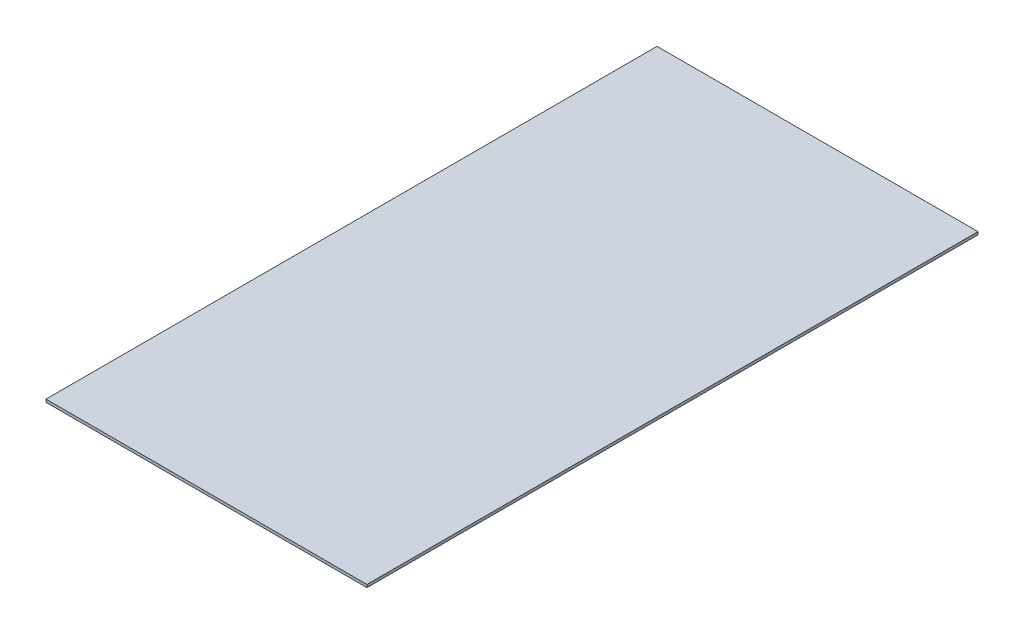
from build123d import *

# Parameters (mm, degrees)
SKETCH_1_W      = 229
SKETCH_1_H      = 436
EXTRUDE_1_DEPTH = 2


with BuildPart() as part:
    # 草图1 → 凸台-拉伸1 (new body)
    with BuildSketch(Plane(origin=(0, 0, 0), x_dir=(1, 0, 0), z_dir=(0, 1, 0))):
        Rectangle(SKETCH_1_W, SKETCH_1_H)
    extrude(amount=EXTRUDE_1_DEPTH)


solid = part.part
